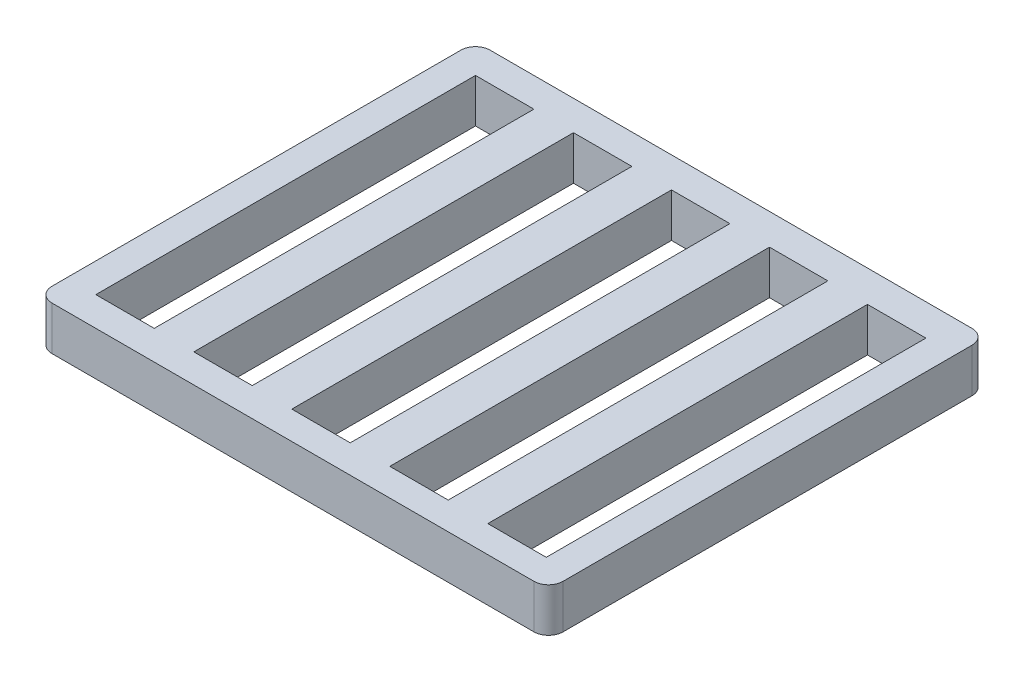
from build123d import *

# Parameters (mm, degrees)
SKETCH1_W           = 350
SKETCH1_H           = 300
BOSS_EXTRUDE1_DEPTH = 30
SKETCH3_W           = 40
SKETCH3_H           = 260
CUT_EXTRUDE1_DEPTH  = 31
FILLET1_R           = 10


with BuildPart() as part:
    # Sketch1 → Boss-Extrude1 (new body)
    with BuildSketch(Plane(origin=(0, 0, 0), x_dir=(1, 0, 0), z_dir=(0, 1, 0))):
        with Locations((175, -150)):
            Rectangle(SKETCH1_W, SKETCH1_H)
    extrude(amount=BOSS_EXTRUDE1_DEPTH)

    # Sketch3 → Cut-Extrude1 (cut, through all)
    with BuildSketch(Plane(origin=(0, 0, 0), x_dir=(-1, 0, 0), z_dir=(0, -1, 0))):
        with Locations((-40, -150)):
            Rectangle(SKETCH3_W, SKETCH3_H)
        with Locations((-107.5, -150.391320706)):
            Rectangle(SKETCH3_W, SKETCH3_H)
        with Locations((-175, -150.782641412)):
            Rectangle(SKETCH3_W, SKETCH3_H)
        with Locations((-242.5, -151.173962118)):
            Rectangle(SKETCH3_W, SKETCH3_H)
        with Locations((-310, -151.565282825)):
            Rectangle(SKETCH3_W, SKETCH3_H)
    extrude(amount=-CUT_EXTRUDE1_DEPTH, mode=Mode.SUBTRACT)

    # Fillet1
    fillet1_edges = [part.edges().sort_by_distance(p)[0] for p in [
        (0, 15, 300),
        (0, 15, 0),
        (350, 15, 0),
        (350, 15, 300),
    ]]
    fillet(fillet1_edges, radius=FILLET1_R)


solid = part.part
